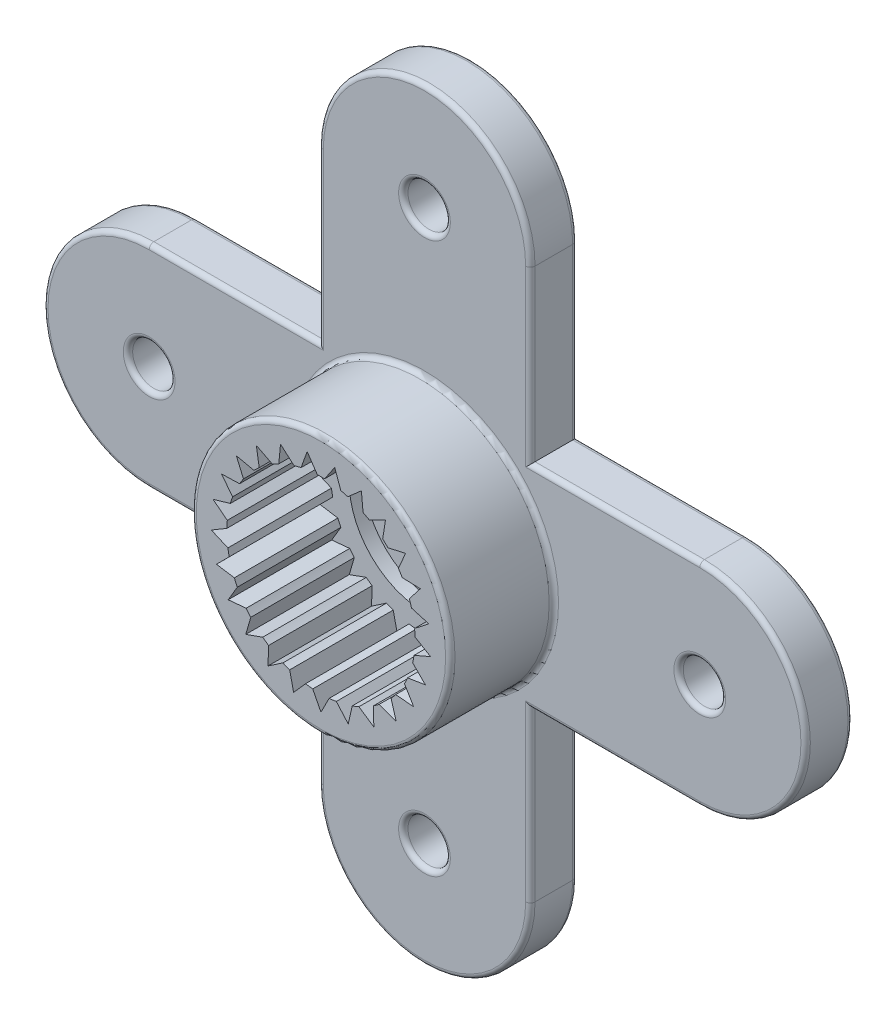
from build123d import *

# Parameters (mm, degrees)
ESQUISSE1_R             = 2.75
BOSS_EXTRU_1_DEPTH      = 1
ESQUISSE2_R             = 2.75
BOSS_EXTRU_2_DEPTH      = 2.2
ESQUISSE3_R             = 2
ENL_V_MAT_EXTRU_1_DEPTH = 2.5
ESQUISSE4_R             = 1.6
ENL_V_MAT_EXTRU_2_DEPTH = 0.4
ESQUISSE5_R             = 0.85
ENL_V_MAT_EXTRU_3_DEPTH = 4.8
ESQUISSE6_R             = 0.45
ENL_V_MAT_EXTRU_4_DEPTH = 4.2
CUT_EXTRUDE1_DEPTH      = 2.5
CIRPATTERN1_COUNT       = 25
BOSS_EXTRUDE1_DEPTH     = 1
SKETCH3_R               = 0.45
CUT_EXTRUDE2_DEPTH      = 4.2
SKETCH5_R               = 1.6
BOSS_EXTRUDE3_DEPTH     = 1
SKETCH9_R               = 0.45
CUT_EXTRUDE6_DEPTH      = 4.2
FILLET5_R               = 0.1


with BuildPart() as part:
    # Esquisse1 → Boss.-Extru.1 (new body)
    with BuildSketch(Plane.XY):
        with BuildLine():
            ThreePointArc((2.25, 5.85), (0, 8.1), (-2.25, 5.85))
            Line((-2.25, 5.85), (-2.25, 1.58113883))
            ThreePointArc((-2.25, 1.58113883), (0, 2.75), (2.25, 1.58113883))
            Line((2.25, 1.58113883), (2.25, 5.85))
        make_face()
        Circle(ESQUISSE1_R)
    extrude(amount=BOSS_EXTRU_1_DEPTH)

    # Esquisse2 → Boss.-Extru.2 (add)
    with BuildSketch(Plane.XY.offset(1)):
        Circle(ESQUISSE2_R)
    extrude(amount=BOSS_EXTRU_2_DEPTH)

    # Esquisse3 → Enlèv. mat.-Extru.1 (cut)
    with BuildSketch(Plane.XY.offset(3.2)):
        Circle(ESQUISSE3_R)
    extrude(amount=-ENL_V_MAT_EXTRU_1_DEPTH, mode=Mode.SUBTRACT)

    # Esquisse4 → Enlèv. mat.-Extru.2 (cut)
    with BuildSketch(Plane(origin=(0, 0, 0), x_dir=(-1, 0, 0), z_dir=(0, 0, -1))):
        Circle(ESQUISSE4_R)
    extrude(amount=-ENL_V_MAT_EXTRU_2_DEPTH, mode=Mode.SUBTRACT)

    # Esquisse5 → Enlèv. mat.-Extru.3 (cut)
    with BuildSketch(Plane(origin=(0, 0, 0.4), x_dir=(-1, 0, 0), z_dir=(0, 0, -1))):
        Circle(ESQUISSE5_R)
    extrude(amount=-ENL_V_MAT_EXTRU_3_DEPTH, mode=Mode.SUBTRACT)

    # Esquisse6 → Enlèv. mat.-Extru.4 (cut, through all)
    with BuildSketch(Plane(origin=(0, 0, 0), x_dir=(-1, 0, 0), z_dir=(0, 0, -1))):
        with Locations((0, 5.85)):
            Circle(ESQUISSE6_R)
    extrude(amount=-ENL_V_MAT_EXTRU_4_DEPTH, mode=Mode.SUBTRACT)

    # Sketch1 → Cut-Extrude1 (cut)
    with BuildSketch(Plane.XY.offset(3.2)):
        with BuildLine():
            Line((0.174311485, -1.992389396), (0, -2.334))
            Line((0, -2.334), (-0.174311485, -1.992389396))
            ThreePointArc((-0.174311485, -1.992389396), (0, -2), (0.174311485, -1.992389396))
        make_face()
    cut_extrude1 = extrude(amount=-CUT_EXTRUDE1_DEPTH, mode=Mode.SUBTRACT)

    # CirPattern1: Cut-Extrude1 ×25 about axis
    cirpattern1_axis = Axis((0, 0, 0), (0, 0, 1))
    for i in range(1, CIRPATTERN1_COUNT):
        add(cut_extrude1.rotate(cirpattern1_axis, i * 360 / CIRPATTERN1_COUNT), mode=Mode.SUBTRACT)

    # Sketch2 → Boss-Extrude1 (add)
    with BuildSketch(Plane(origin=(0, 0, 0), x_dir=(-1, 0, 0), z_dir=(0, 0, -1))):
        with BuildLine():
            Line((2.25, -1.58113883), (2.25, -5.85))
            ThreePointArc((2.25, -5.85), (0, -8.1), (-2.25, -5.85))
            Line((-2.25, -5.85), (-2.25, -1.58113883))
            ThreePointArc((-2.25, -1.58113883), (0, -2.75), (2.25, -1.58113883))
        make_face()
    extrude(amount=-BOSS_EXTRUDE1_DEPTH)

    # Sketch3 → Cut-Extrude2 (cut, through all)
    with BuildSketch(Plane(origin=(0, 0, 0), x_dir=(-1, 0, 0), z_dir=(0, 0, -1))):
        with Locations((0, -5.85)):
            Circle(SKETCH3_R)
    extrude(amount=-CUT_EXTRUDE2_DEPTH, mode=Mode.SUBTRACT)

    # Sketch5 → Boss-Extrude3 (add)
    with BuildSketch(Plane(origin=(0, 0, 0), x_dir=(-1, 0, 0), z_dir=(0, 0, -1))):
        with BuildLine():
            Line((5.85, 2.25), (-5.85, 2.25))
            ThreePointArc((-5.85, 2.25), (-8.1, 0), (-5.85, -2.25))
            Line((-5.85, -2.25), (5.85, -2.25))
            ThreePointArc((5.85, -2.25), (8.1, 0), (5.85, 2.25))
        make_face()
        Circle(SKETCH5_R, mode=Mode.SUBTRACT)
    extrude(amount=-BOSS_EXTRUDE3_DEPTH)

    # Sketch9 → Cut-Extrude6 (cut, through all)
    with BuildSketch(Plane(origin=(0, 0, 0), x_dir=(-1, 0, 0), z_dir=(0, 0, -1))):
        with Locations((5.85, 0)):
            Circle(SKETCH9_R)
        with Locations((-5.85, 0)):
            Circle(SKETCH9_R)
    extrude(amount=-CUT_EXTRUDE6_DEPTH, mode=Mode.SUBTRACT)

    # Fillet5
    fillet5_edges = [part.edges().sort_by_distance(p)[0] for p in [
        (-2.25, 4.05, 1),
        (-2.75, 0, 1),
        (-2.75, 0, 3.2),
        (1.6, 0, 0),
        (0, -8.1, 1),
        (0, -8.1, 0),
        (0.45, -5.85, 1),
        (0.45, -5.85, 0),
        (-2.25, -4.05, 1),
        (-2.25, -4.05, 0),
        (2.25, -4.05, 1),
        (2.25, -4.05, 0),
        (0.45, 5.85, 1),
        (0.45, 5.85, 0),
        (-4.05, 2.25, 1),
        (4.05, 2.25, 1),
        (-4.05, -2.25, 1),
        (-4.05, 2.25, 0),
        (-4.05, -2.25, 0),
        (-8.1, 0, 0),
        (-8.1, 0, 1),
        (4.05, -2.25, 1),
        (8.1, 0, 1),
        (4.05, 2.25, 0),
        (8.1, 0, 0),
        (4.05, -2.25, 0),
        (2.25, 4.05, 1),
        (-5.4, 0, 1),
        (-5.4, 0, 0),
        (6.3, 0, 1),
        (6.3, 0, 0),
        (-2.25, 4.05, 0),
        (0, 8.1, 0),
        (2.25, 4.05, 0),
        (0, 8.1, 1),
    ]]
    fillet(fillet5_edges, radius=FILLET5_R)


solid = part.part
